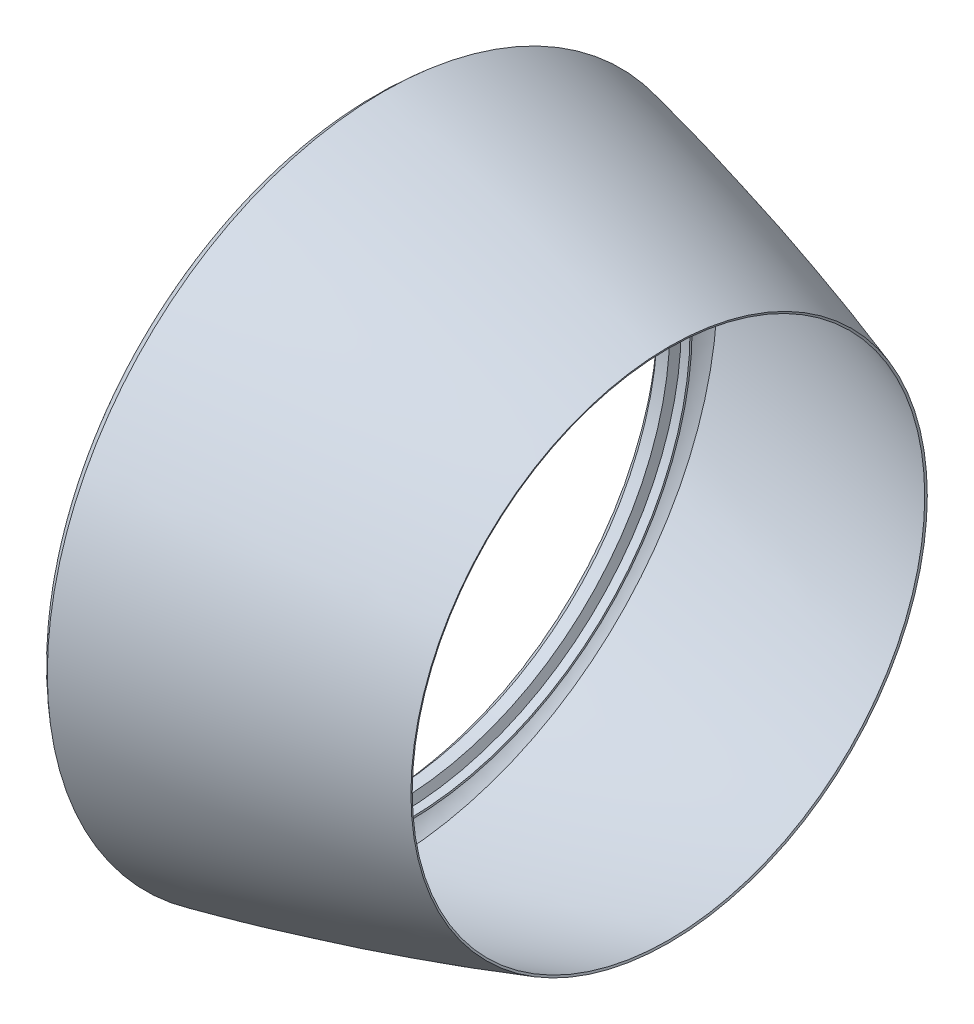
from build123d import *

# Parameters (mm, degrees)
THICKEN1_T1 = 5


with BuildPart() as body_1:
    # Surface-Revolve1: a surface, the sketch's curves turned about an axis
    with BuildLine(Plane.XY, mode=Mode.PRIVATE) as surface_revolve1_1_path:
        Line((58.164522356, 700), (33.164522356, 700))
        Line((33.164522356, 700), (25, 680))
        Line((25, 680), (0, 680))
        add(Edge.make_bspline(
            [(0, 680), (-82.223025066, 754.635531887), (0, 820.403746947)],
            knots=[0, 0, 0, 1, 1, 1], degree=2))
        add(Edge.make_bspline(
            [(0, 820.403746947), (355.230240406, 744.426095971), (700, 630)],
            knots=[0, 0, 0, 1, 1, 1], degree=2))
    surface_revolve1_1 = Shell.revolve(surface_revolve1_1_path.wire(), 360, Axis((0, 0, 0), (1, 0, 0)))
    add(Solid.thicken(surface_revolve1_1, THICKEN1_T1))


solid = body_1.part
